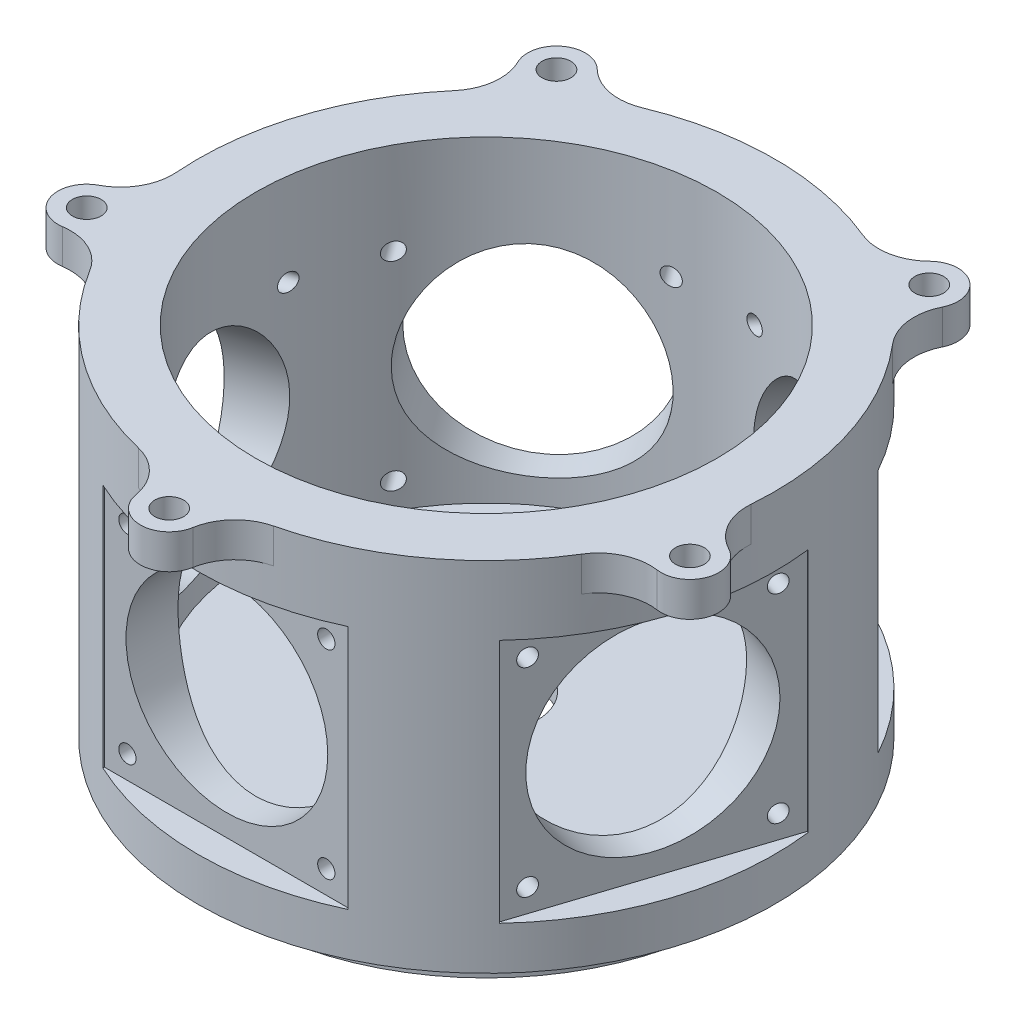
from build123d import *

# Parameters (mm, degrees)
SKETCH1_R           = 100
BOSS_EXTRUDE1_DEPTH = 124
SKETCH2_R           = 5
BOSS_EXTRUDE2_DEPTH = 12
CIRPATTERN3_COUNT   = 5
SKETCH3_R           = 85
SKETCH3_R_2         = 80
EXTRUDE_THIN1_DEPTH = 12
SKETCH4_R           = 80
CUT_EXTRUDE1_DEPTH  = 6
SKETCH5_W           = 85
SKETCH5_H           = 85
CUT_EXTRUDE2_DEPTH  = 10
SKETCH9_R           = 80
CUT_EXTRUDE4_DEPTH  = 110
CUT_EXTRUDE5_START  = -19.33353
SKETCH10_R          = 35
SKETCH10_R_2        = 3
CUT_EXTRUDE5_DEPTH  = 19.33353
CIRPATTERN5_COUNT   = 5
SKETCH11_R          = 17.5
CUT_EXTRUDE6_DEPTH  = 119.0000001


with BuildPart() as part:
    # Sketch1 → Boss-Extrude1 (new body)
    with BuildSketch(Plane(origin=(0, 0, 0), x_dir=(1, 0, 0), z_dir=(0, 1, 0))):
        Circle(SKETCH1_R)
    extrude(amount=BOSS_EXTRUDE1_DEPTH)

    # Sketch2 → Boss-Extrude2 (add)
    with BuildSketch(Plane(origin=(0, 124, 0), x_dir=(1, 0, 0), z_dir=(0, 1, 0))):
        with BuildLine():
            ThreePointArc((-23.388186084, -97.226502311), (-14.454510342, -102.429016207), (-9.85644985, -111.688311688))
            ThreePointArc((-9.85644985, -111.688311688), (0, -120), (9.85644985, -111.688311688))
            ThreePointArc((9.85644985, -111.688311688), (14.454510342, -102.429016207), (23.388186084, -97.226502311))
            ThreePointArc((23.388186084, -97.226502311), (0, -100), (-23.388186084, -97.226502311))
        make_face()
        with Locations((0, -110)):
            Circle(SKETCH2_R, mode=Mode.SUBTRACT)
    boss_extrude2 = extrude(amount=-BOSS_EXTRUDE2_DEPTH)

    # CirPattern3: Boss-Extrude2 ×5 about axis
    cirpattern3_axis = Axis((0, 0, 0), (0, 1, 0))
    for i in range(1, CIRPATTERN3_COUNT):
        add(boss_extrude2.rotate(cirpattern3_axis, i * 360 / CIRPATTERN3_COUNT))

    # Sketch3 → Extrude-Thin1 (add)
    with BuildSketch(Plane.XZ):
        Circle(SKETCH3_R)
        Circle(SKETCH3_R_2, mode=Mode.SUBTRACT)
    extrude(amount=EXTRUDE_THIN1_DEPTH)

    # Sketch4 → Cut-Extrude1 (cut)
    with BuildSketch(Plane.XZ):
        Circle(SKETCH4_R)
    extrude(amount=-CUT_EXTRUDE1_DEPTH, mode=Mode.SUBTRACT)

    # Sketch5 → Cut-Extrude2 (cut)
    with BuildSketch(Plane.XY.offset(100)):
        with Locations((0, 57.5)):
            Rectangle(SKETCH5_W, SKETCH5_H)
    cut_extrude2 = extrude(amount=-CUT_EXTRUDE2_DEPTH, mode=Mode.SUBTRACT)

    # Sketch9 → Cut-Extrude4 (cut)
    with BuildSketch(Plane(origin=(0, 124, 0), x_dir=(1, 0, 0), z_dir=(0, 1, 0))):
        Circle(SKETCH9_R)
    extrude(amount=-CUT_EXTRUDE4_DEPTH, mode=Mode.SUBTRACT)

    # Sketch10 → Cut-Extrude5 (cut)
    with BuildSketch(Plane.XY.offset(90).offset(CUT_EXTRUDE5_START)):
        with Locations((0, 57.5)):
            Circle(SKETCH10_R)
        with Locations((-34.5, 92)):
            Circle(SKETCH10_R_2)
        with Locations((34.5, 92)):
            Circle(SKETCH10_R_2)
        with Locations((-34.5, 23)):
            Circle(SKETCH10_R_2)
        with Locations((34.5, 23)):
            Circle(SKETCH10_R_2)
    cut_extrude5 = extrude(amount=CUT_EXTRUDE5_DEPTH, mode=Mode.SUBTRACT)

    # CirPattern5: Cut-Extrude2, Cut-Extrude5 ×5 about axis
    cirpattern5_axis = Axis((0, 0, 0), (0, 1, 0))
    for i in range(1, CIRPATTERN5_COUNT):
        add(cut_extrude2.rotate(cirpattern5_axis, i * 360 / CIRPATTERN5_COUNT), mode=Mode.SUBTRACT)
        add(cut_extrude5.rotate(cirpattern5_axis, i * 360 / CIRPATTERN5_COUNT), mode=Mode.SUBTRACT)

    # Sketch11 → Cut-Extrude6 (cut, through all)
    with BuildSketch(Plane.XZ.offset(-6)):
        Circle(SKETCH11_R)
    extrude(amount=-CUT_EXTRUDE6_DEPTH, mode=Mode.SUBTRACT)


solid = part.part
